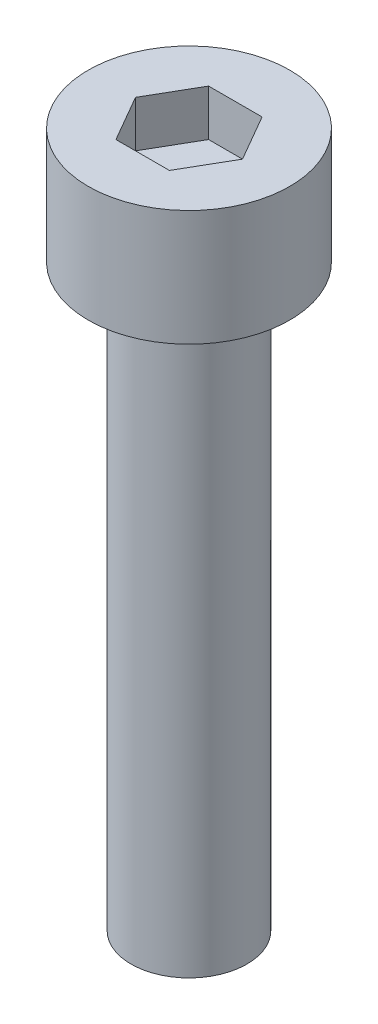
from build123d import *

# Parameters (mm, degrees)
SKETCH_1_R          = 4.35
EXTRUDE_1_DEPTH     = 5
CUT_EXTRUDE_1_DEPTH = 2
SKETCH_3_R          = 2.5
EXTRUDE_2_DEPTH     = 25


with BuildPart() as part:
    # 草图1 → 凸台-拉伸1 (new body)
    with BuildSketch(Plane(origin=(0, 0, 0), x_dir=(1, 0, 0), z_dir=(0, 1, 0))):
        Circle(SKETCH_1_R)
    extrude(amount=EXTRUDE_1_DEPTH)

    # 草图2 → 切除-拉伸1 (cut)
    with BuildSketch(Plane(origin=(0, 5, 0), x_dir=(1, 0, 0), z_dir=(0, 1, 0))):
        Polygon((2.309401077, 0), (1.154700538, 2), (-1.154700538, 2), (-2.309401077, 0), (-1.154700538, -2), (1.154700538, -2), align=None)
    extrude(amount=-CUT_EXTRUDE_1_DEPTH, mode=Mode.SUBTRACT)

    # 草图3 → 凸台-拉伸2 (add)
    with BuildSketch(Plane.XZ):
        Circle(SKETCH_3_R)
    extrude(amount=EXTRUDE_2_DEPTH)


solid = part.part
